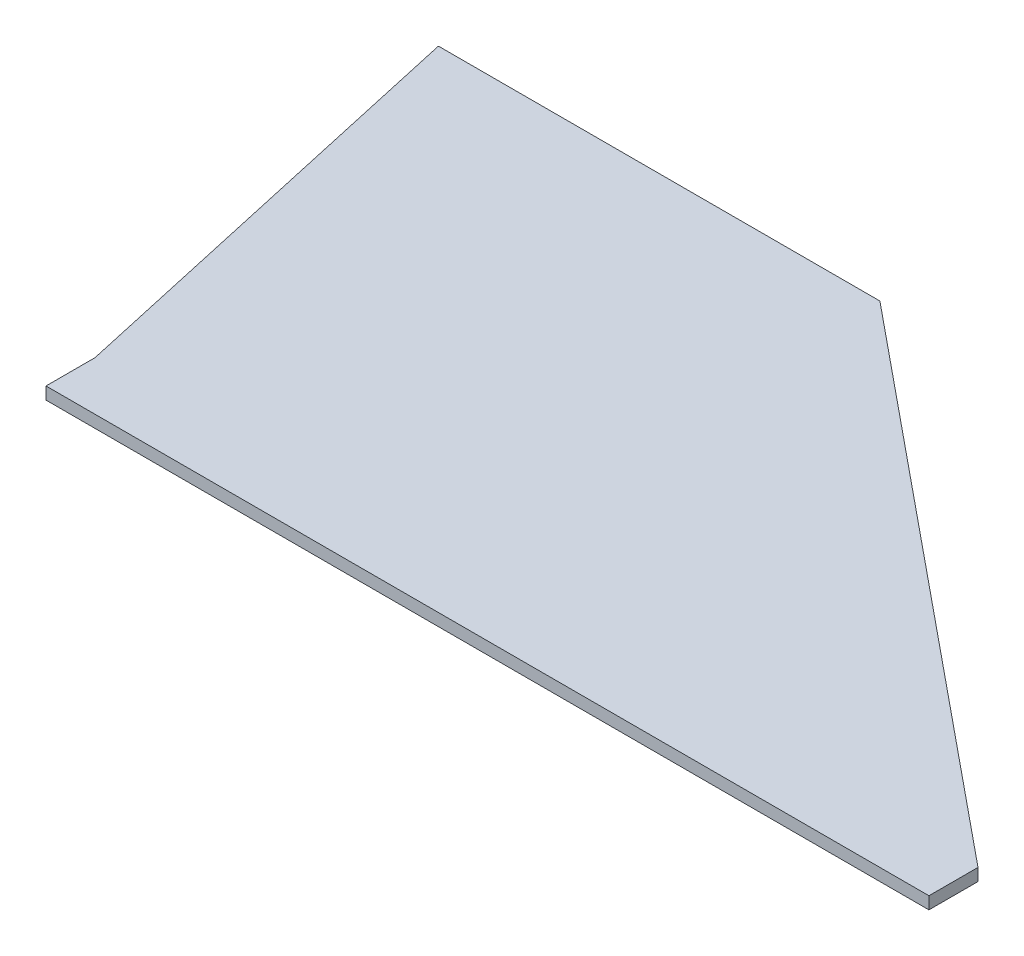
from build123d import *

# Parameters (mm, degrees)
BOSS_EXTRUDE1_DEPTH = 6.35


with BuildPart() as part:
    # Sketch1 → Boss-Extrude1 (new body)
    with BuildSketch(Plane(origin=(0, 0, 0), x_dir=(1, 0, 0), z_dir=(0, 1, 0))):
        Polygon((0, 25.4), (-50.8, 254), (177.8, 254), (457.2, 25.4), (457.2, 0), (0, 0), align=None)
    extrude(amount=BOSS_EXTRUDE1_DEPTH)


solid = part.part
